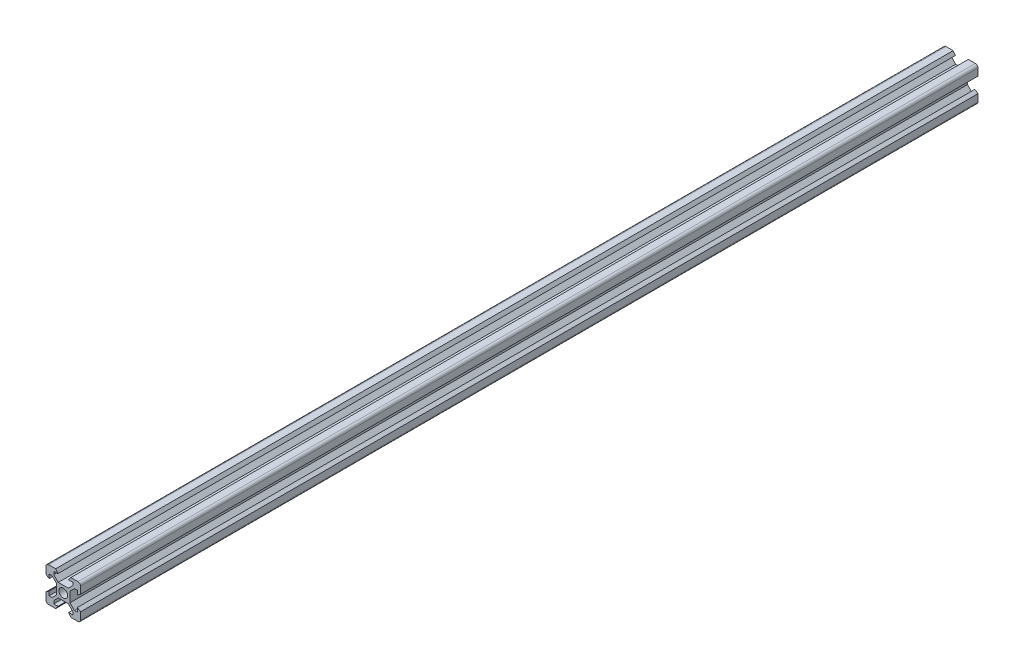
from build123d import *

# Parameters (mm, degrees)
SKETCH_1_R      = 2.5
EXTRUDE_1_DEPTH = 520


with BuildPart() as part:
    # 草图1 → 凸台-拉伸1 (new body)
    with BuildSketch(Plane.XY):
        with BuildLine():
            Line((14.8, 34.821428571), (18.9, 34.821428571))
            Line((18.9, 34.821428571), (20.2, 33.021428571))
            Line((20.2, 33.021428571), (17.8, 33.021428571))
            Line((17.8, 33.021428571), (17.8, 31.311378065))
            Line((17.8, 31.311378065), (20.389949494, 28.721428571))
            Line((20.389949494, 28.721428571), (26.210050506, 28.721428571))
            Line((26.210050506, 28.721428571), (28.8, 31.311378065))
            Line((28.8, 31.311378065), (28.8, 33.021428571))
            Line((28.8, 33.021428571), (26.4, 33.021428571))
            Line((26.4, 33.021428571), (27.7, 34.821428571))
            Line((27.7, 34.821428571), (31.8, 34.821428571))
            ThreePointArc((31.8, 34.821428571), (32.860660172, 34.382088743), (33.3, 33.321428571))
            Line((33.3, 33.321428571), (33.3, 29.221428571))
            Line((33.3, 29.221428571), (31.5, 27.921428571))
            Line((31.5, 27.921428571), (31.5, 30.321428571))
            Line((31.5, 30.321428571), (29.789949494, 30.321428571))
            Line((29.789949494, 30.321428571), (27.2, 27.731479078))
            Line((27.2, 27.731479078), (27.2, 21.911378065))
            Line((27.2, 21.911378065), (29.789949494, 19.321428571))
            Line((29.789949494, 19.321428571), (31.5, 19.321428571))
            Line((31.5, 19.321428571), (31.5, 21.721428571))
            Line((31.5, 21.721428571), (33.3, 20.421428571))
            Line((33.3, 20.421428571), (33.3, 16.321428571))
            ThreePointArc((33.3, 16.321428571), (32.860660172, 15.2607684), (31.8, 14.821428571))
            Line((31.8, 14.821428571), (27.7, 14.821428571))
            Line((27.7, 14.821428571), (26.4, 16.621428571))
            Line((26.4, 16.621428571), (28.8, 16.621428571))
            Line((28.8, 16.621428571), (28.8, 18.331479078))
            Line((28.8, 18.331479078), (26.210050506, 20.921428571))
            Line((26.210050506, 20.921428571), (20.389949494, 20.921428571))
            Line((20.389949494, 20.921428571), (17.8, 18.331479078))
            Line((17.8, 18.331479078), (17.8, 16.621428571))
            Line((17.8, 16.621428571), (20.2, 16.621428571))
            Line((20.2, 16.621428571), (18.9, 14.821428571))
            Line((18.9, 14.821428571), (14.8, 14.821428571))
            ThreePointArc((14.8, 14.821428571), (13.739339828, 15.2607684), (13.3, 16.321428571))
            Line((13.3, 16.321428571), (13.3, 20.421428571))
            Line((13.3, 20.421428571), (15.1, 21.721428571))
            Line((15.1, 21.721428571), (15.1, 19.321428571))
            Line((15.1, 19.321428571), (16.810050506, 19.321428571))
            Line((16.810050506, 19.321428571), (19.4, 21.911378065))
            Line((19.4, 21.911378065), (19.4, 27.731479078))
            Line((19.4, 27.731479078), (16.810050506, 30.321428571))
            Line((16.810050506, 30.321428571), (15.1, 30.321428571))
            Line((15.1, 30.321428571), (15.1, 27.921428571))
            Line((15.1, 27.921428571), (13.3, 29.221428571))
            Line((13.3, 29.221428571), (13.3, 33.321428571))
            ThreePointArc((13.3, 33.321428571), (13.739339828, 34.382088743), (14.8, 34.821428571))
        make_face()
        with Locations((23.3, 24.821428571)):
            Circle(SKETCH_1_R, mode=Mode.SUBTRACT)
    extrude(amount=EXTRUDE_1_DEPTH)


solid = part.part
